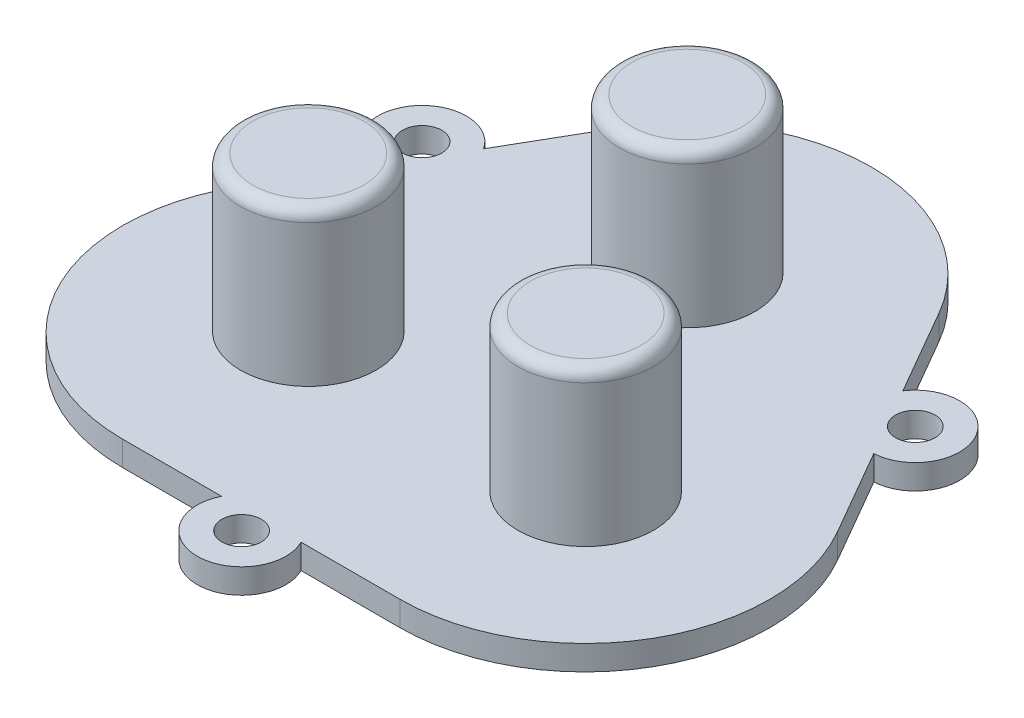
from build123d import *

# Parameters (mm, degrees)
SKETCH5_R           = 1.6
BOSS_EXTRUDE2_DEPTH = 2
SKETCH6_R           = 5.5
BOSS_EXTRUDE3_DEPTH = 14.5
FILLET1_R           = 1
SKETCH7_R           = 0.5
BOSS_EXTRUDE4_DEPTH = 0.6


with BuildPart() as part:
    # Sketch5 → Boss-Extrude2 (new body)
    with BuildSketch(Plane(origin=(0, 0, 0), x_dir=(1, 0, 0), z_dir=(0, 1, 0))):
        with BuildLine():
            Line((-11.250000051, -22.142785594), (-3.22490315, -22.142785594))
            ThreePointArc((-3.22490315, -22.142785594), (-5.1e-08, -27.342785594), (3.224903048, -22.142785594))
            Line((3.224903048, -22.142785594), (11.249999949, -22.142785594))
            ThreePointArc((11.249999949, -22.142785594), (24.240381006, -14.642785594), (24.240381006, 0.357214406))
            Line((24.240381006, 0.357214406), (20.227832555, 7.30715219))
            ThreePointArc((20.227832555, 7.30715219), (23.118713105, 12.700000199), (17.002929456, 12.892848208))
            Line((17.002929456, 12.892848208), (12.990381006, 19.842785992))
            ThreePointArc((12.990381006, 19.842785992), (-5.1e-08, 27.342785992), (-12.990381108, 19.842785992))
            Line((-12.990381108, 19.842785992), (-17.002929558, 12.892848208))
            ThreePointArc((-17.002929558, 12.892848208), (-23.118713208, 12.700000199), (-20.227832658, 7.30715219))
            Line((-20.227832658, 7.30715219), (-24.240381108, 0.357214406))
            ThreePointArc((-24.240381108, 0.357214406), (-24.240381108, -14.642785594), (-11.250000051, -22.142785594))
        make_face()
        with Locations((20.001021652, 10.900000199)):
            Circle(SKETCH5_R, mode=Mode.SUBTRACT)
        with Locations((-5.1e-08, -23.742785594)):
            Circle(SKETCH5_R, mode=Mode.SUBTRACT)
        with Locations((-20.001021754, 10.900000199)):
            Circle(SKETCH5_R, mode=Mode.SUBTRACT)
    extrude(amount=BOSS_EXTRUDE2_DEPTH)

    # Sketch6 → Boss-Extrude3 (add)
    with BuildSketch(Plane(origin=(0, 0, 0), x_dir=(1, 0, 0), z_dir=(0, 1, 0))):
        with Locations((-0.060025126, 12.462836141)):
            Circle(SKETCH6_R)
        with Locations((11.189974874, -7.022735444)):
            Circle(SKETCH6_R)
        with Locations((-11.310025126, -7.022735444)):
            Circle(SKETCH6_R)
    extrude(amount=BOSS_EXTRUDE3_DEPTH)

    # Fillet1
    fillet1_edges = [part.edges().sort_by_distance(p)[0] for p in [
        (-5.560025126, 14.5, -12.462836141),
        (5.689974874, 14.5, 7.022735444),
        (-16.810025126, 14.5, 7.022735444),
    ]]
    fillet(fillet1_edges, radius=FILLET1_R)

    # Sketch7 → Boss-Extrude4 (add)
    with BuildSketch(Plane(origin=(-18.334964206, 0, -10.58569652), x_dir=(-0.5, 0, 0.866025404), z_dir=(-0.866025404, 0, -0.5))):
        with Locations((-9.600955549, 1)):
            Circle(SKETCH7_R)
        with Locations((-7.600955549, 1)):
            Circle(SKETCH7_R)
    extrude(amount=BOSS_EXTRUDE4_DEPTH)


solid = part.part
